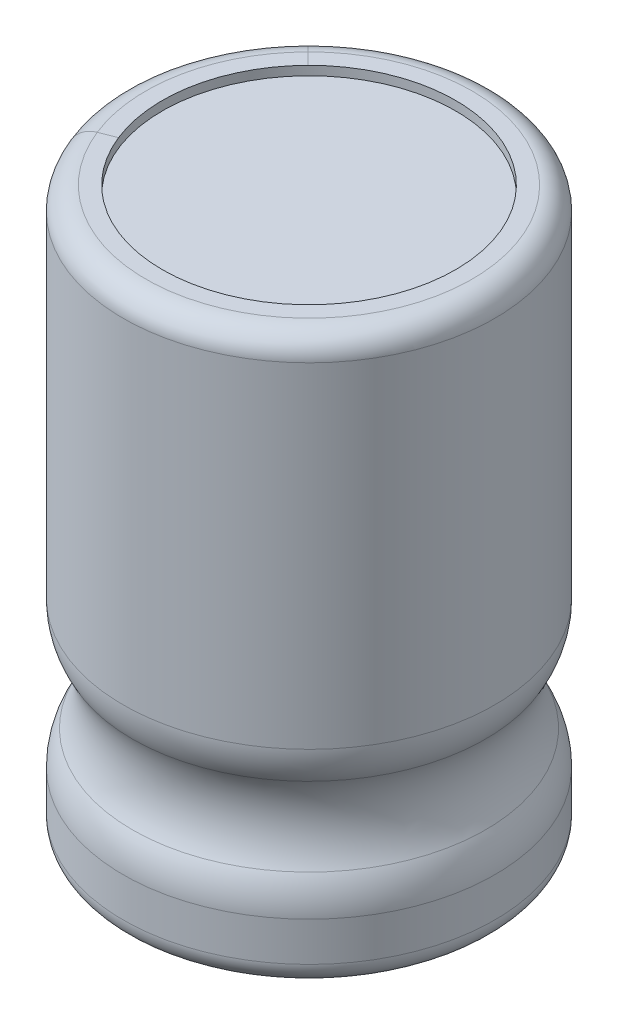
from build123d import *

# Parameters (mm, degrees)
CROQUIS1_R            = 4.1
EXTRUIR1_DEPTH        = 12.5
CROQUIS2_R            = 1.721107575
REDONDEO1_R           = 0.5
REDONDEO2_R           = 1.5
CROQUIS3_R            = 3.23696878
CORTAR_EXTRUIR1_DEPTH = 0.2


with BuildPart() as part:
    # Croquis1 → Extruir1 (new body)
    with BuildSketch(Plane(origin=(0, 0, 0), x_dir=(1, 0, 0), z_dir=(0, 1, 0))):
        Circle(CROQUIS1_R)
    extrude(amount=EXTRUIR1_DEPTH)

    # Croquis2 → Cortar-Revolución1 (revolve, cut)
    with BuildSketch(Plane(origin=(0, 0, 0), x_dir=(0, 0, -1), z_dir=(1, 0, 0))):
        with Locations((5.382002142, 2.987795872)):
            Circle(CROQUIS2_R)
    revolve(axis=Axis((0, 12.5, 0), (0, 1, 0)), mode=Mode.SUBTRACT)

    # Redondeo1
    redondeo1_edges = [part.edges().sort_by_distance(p)[0] for p in [
        (-4.1, 0, 0),
        (-4.1, 12.5, 0),
    ]]
    fillet(redondeo1_edges, radius=REDONDEO1_R)

    # Redondeo2
    redondeo2_edges = [part.edges().sort_by_distance(p)[0] for p in [
        (2.899137803, 4.136134582, -2.899137803),
        (-2.899137803, 1.839457161, 2.899137803),
    ]]
    fillet(redondeo2_edges, radius=REDONDEO2_R)

    # Croquis3 → Cortar-Extruir1 (cut)
    with BuildSketch(Plane(origin=(0, 12.5, 0), x_dir=(1, 0, 0), z_dir=(0, 1, 0))):
        Circle(CROQUIS3_R)
    extrude(amount=-CORTAR_EXTRUIR1_DEPTH, mode=Mode.SUBTRACT)


solid = part.part
